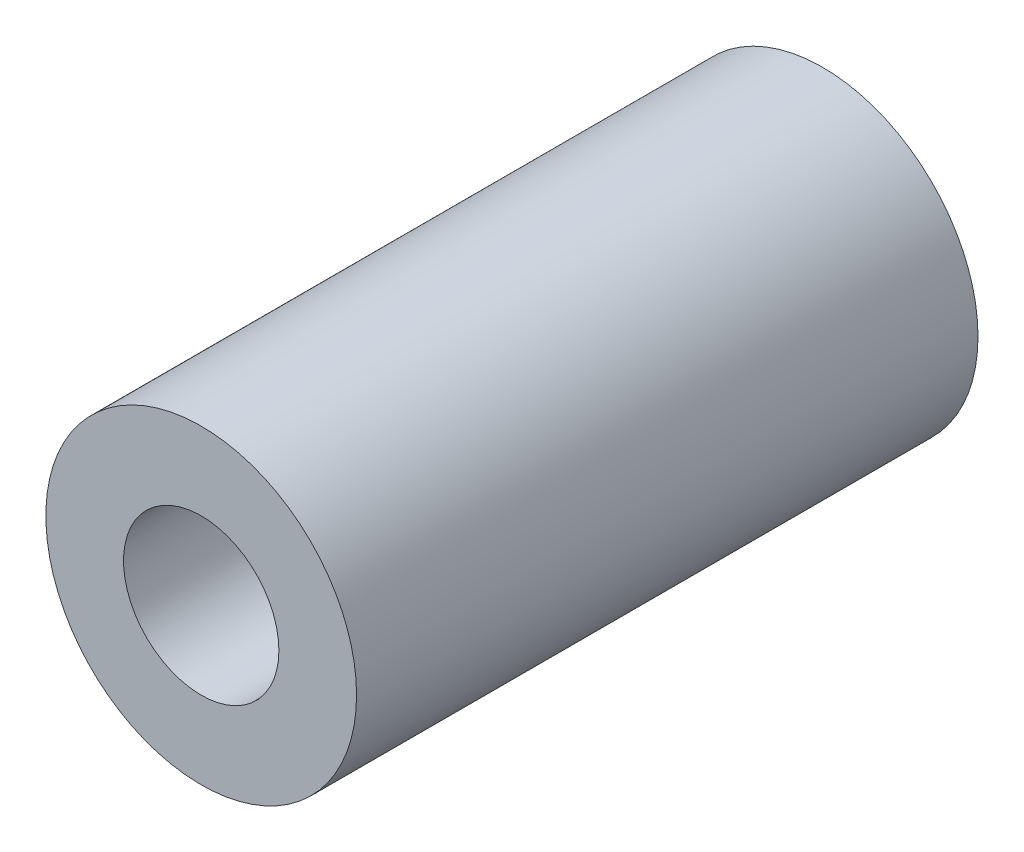
from build123d import *

# Parameters (mm, degrees)
SKETCH_1_R         = 2.5
EXTRUDE_1_DEPTH    = 10
HOLE_WIZARD_M3_1_D = 2.5


with BuildPart() as part:
    # 草图1 → 凸台-拉伸1 (new body)
    with BuildSketch(Plane.XY):
        Circle(SKETCH_1_R)
    extrude(amount=EXTRUDE_1_DEPTH)

    # M3 螺纹孔1 (through all)
    with Locations(Plane.XY.offset(10)):
        with Locations((0, 0)):
            Hole(HOLE_WIZARD_M3_1_D / 2)


solid = part.part
